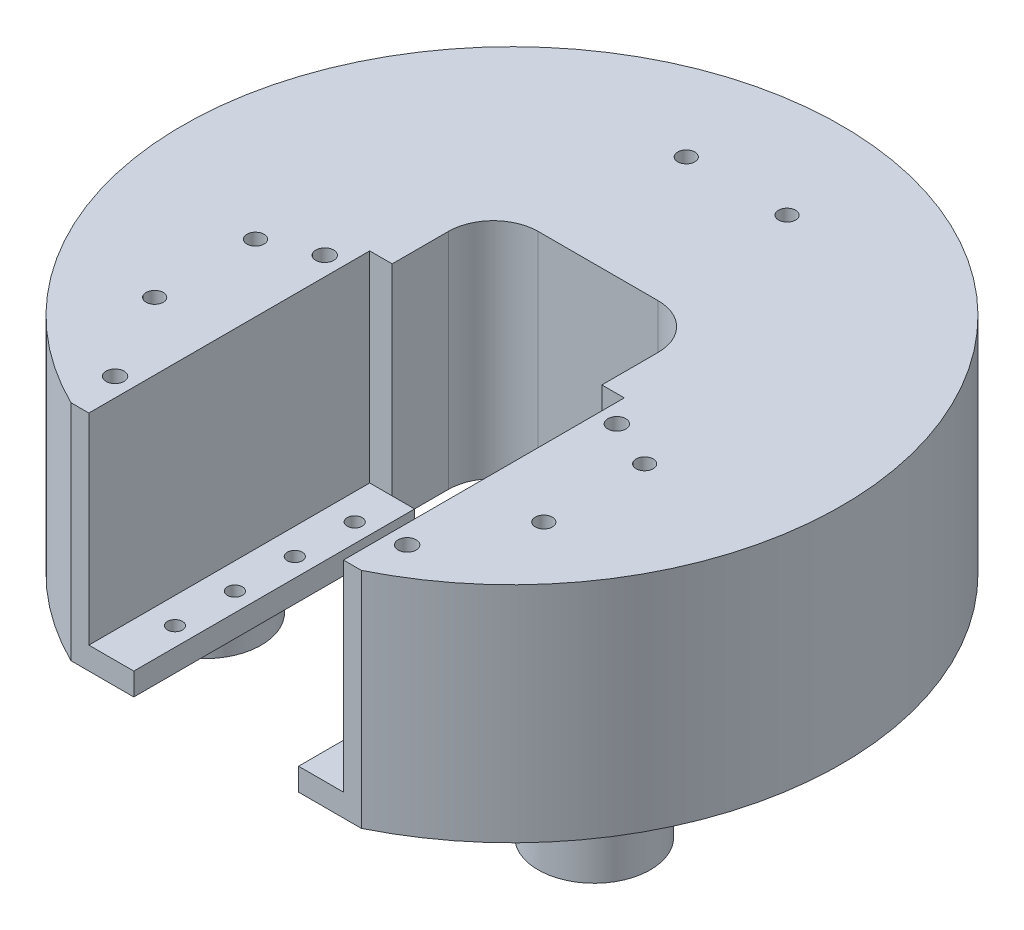
from build123d import *

# Parameters (mm, degrees)
IZIM2_R                                        = 44
Y_KSEKLIK_EKSTR_ZYON1_DEPTH                    = 48
IZIM3_R                                        = 11
KES_EKSTR_ZYON1_DEPTH                          = 35
SERVO_MOTOR_BO_LU_U_REACH                      = 15
IZIM5_R                                        = 5.5
IZIM5_W                                        = 20
IZIM5_H                                        = 6.5
IZIM5_W_2                                      = 6
IZIM5_H_2                                      = 7.2
IZIM6_W                                        = 120
IZIM6_H                                        = 25
KES_EKSTR_ZYON3_DEPTH                          = 49
IZIM7_W                                        = 34
IZIM7_H                                        = 10
KES_EKSTR_ZYON4_DEPTH                          = 37.5
IZIM8_R                                        = 5.5
IZIM8_W                                        = 20
IZIM8_H                                        = 6.5
KES_EKSTR_ZYON5_DEPTH                          = 14
M2_D_Z_BA_L_MAKINE_VIDAS_IN_HAV_A1_D           = 2
M2_D_Z_BA_L_MAKINE_VIDAS_IN_HAV_A1_DEPTH       = 3
M2_D_Z_BA_L_MAKINE_VIDAS_IN_HAV_A1_CSINK_D     = 2.6
M2_D_Z_BA_L_MAKINE_VIDAS_IN_HAV_A1_CSINK_ANGLE = 90
IZIM11_R                                       = 47.5
KES_EKSTR_ZYON6_DEPTH                          = 8.16
IZIM14_R                                       = 47.5
KES_EKSTR_ZYON7_DEPTH                          = 10
IZIM13_R                                       = 7.5
TABAN_AYAKLAR_DEPTH                            = 10
DAIRESEL_KAPLAMA1_COUNT                        = 3
F_3_8_Z_VANA_IN_BORU_Z_VANA_MATKAB_1_D         = 2.286
F_3_8_Z_VANA_IN_BORU_Z_VANA_MATKAB_1_DEPTH     = 10
IZIM18_R                                       = 1.2
KES_EKSTR_ZYON8_DEPTH                          = 10


with BuildPart() as part:
    # Çizim2 → Yükseklik-Ekstrüzyon1 (new body)
    with BuildSketch(Plane(origin=(0, 0, 0), x_dir=(1, 0, 0), z_dir=(0, 1, 0))):
        Circle(IZIM2_R)
    extrude(amount=Y_KSEKLIK_EKSTR_ZYON1_DEPTH)

    # Çizim3 → Kes-Ekstrüzyon1 (cut)
    with BuildSketch(Plane(origin=(0, 48, 0), x_dir=(1, 0, 0), z_dir=(0, 1, 0))):
        Circle(IZIM3_R)
        Polygon((-14, -2), (14, -2), (17, -2), (17, -39.5), (-17, -39.5), (-17, -2), align=None)
        with BuildLine():
            Line((-8, 11.5), (8, 11.5))
            ThreePointArc((8, 11.5), (12.242640687, 9.742640687), (14, 5.5))
            Line((14, 5.5), (14, -2))
            Line((14, -2), (-14, -2))
            Line((-14, -2), (-14, 5.5))
            ThreePointArc((-14, 5.5), (-12.242640687, 9.742640687), (-8, 11.5))
        make_face()
        with BuildLine():
            ThreePointArc((11, 0), (-1.004193186, 10.954067557), (-10.816653826, -2))
            Line((-10.816653826, -2), (10.816653826, -2))
            ThreePointArc((10.816653826, -2), (10.954067557, -1.004193186), (11, 0))
        make_face()
        with BuildLine():
            Line((10.816653826, -2), (-10.816653826, -2))
            ThreePointArc((-10.816653826, -2), (0, -11), (10.816653826, -2))
        make_face()
    extrude(amount=-KES_EKSTR_ZYON1_DEPTH, mode=Mode.SUBTRACT)

    # Çizim5 → Servo Motor Boşluğu (cut, up to next)
    with BuildSketch(Plane(origin=(0, 13, 0), x_dir=(1, 0, 0), z_dir=(0, 1, 0)), mode=Mode.PRIVATE) as servo_motor_bo_lu_u_sk1:
        Circle(IZIM5_R)
    servo_motor_bo_lu_u_tool1 = extrude(servo_motor_bo_lu_u_sk1.sketch, amount=-SERVO_MOTOR_BO_LU_U_REACH, mode=Mode.PRIVATE) & part.part
    add(servo_motor_bo_lu_u_tool1.solids().sort_by_distance((0, 13, 0))[0], mode=Mode.SUBTRACT)
    # Çizim5 → Servo Motor Boşluğu (cut, up to next)
    with BuildSketch(Plane(origin=(0, 13, 0), x_dir=(1, 0, 0), z_dir=(0, 1, 0)), mode=Mode.PRIVATE) as servo_motor_bo_lu_u_sk2:
        with Locations((0, -16.35)):
            Rectangle(IZIM5_W, IZIM5_H)
    servo_motor_bo_lu_u_tool2 = extrude(servo_motor_bo_lu_u_sk2.sketch, amount=-SERVO_MOTOR_BO_LU_U_REACH, mode=Mode.PRIVATE) & part.part
    add(servo_motor_bo_lu_u_tool2.solids().sort_by_distance((0, 13, 16.35))[0], mode=Mode.SUBTRACT)
    # Çizim5 → Servo Motor Boşluğu (cut, up to next)
    with BuildSketch(Plane(origin=(0, 13, 0), x_dir=(1, 0, 0), z_dir=(0, 1, 0)), mode=Mode.PRIVATE) as servo_motor_bo_lu_u_sk3:
        with Locations((-8, -29.9)):
            Rectangle(IZIM5_W_2, IZIM5_H_2)
    servo_motor_bo_lu_u_tool3 = extrude(servo_motor_bo_lu_u_sk3.sketch, amount=-SERVO_MOTOR_BO_LU_U_REACH, mode=Mode.PRIVATE) & part.part
    add(servo_motor_bo_lu_u_tool3.solids().sort_by_distance((-8, 13, 29.9))[0], mode=Mode.SUBTRACT)
    # Çizim5 → Servo Motor Boşluğu (cut, up to next)
    with BuildSketch(Plane(origin=(0, 13, 0), x_dir=(1, 0, 0), z_dir=(0, 1, 0)), mode=Mode.PRIVATE) as servo_motor_bo_lu_u_sk4:
        with Locations((8, -29.9)):
            Rectangle(IZIM5_W_2, IZIM5_H_2)
    servo_motor_bo_lu_u_tool4 = extrude(servo_motor_bo_lu_u_sk4.sketch, amount=-SERVO_MOTOR_BO_LU_U_REACH, mode=Mode.PRIVATE) & part.part
    add(servo_motor_bo_lu_u_tool4.solids().sort_by_distance((8, 13, 29.9))[0], mode=Mode.SUBTRACT)

    # Çizim6 → Kes-Ekstrüzyon3 (cut, through all)
    with BuildSketch(Plane(origin=(0, 48, 0), x_dir=(1, 0, 0), z_dir=(0, 1, 0))):
        with Locations((0, -52)):
            Rectangle(IZIM6_W, IZIM6_H)
    extrude(amount=-KES_EKSTR_ZYON3_DEPTH, mode=Mode.SUBTRACT)

    # Çizim7 → Kes-Ekstrüzyon4 (cut)
    with BuildSketch(Plane.XY.offset(39.5)):
        with Locations((0, 5)):
            Rectangle(IZIM7_W, IZIM7_H)
    extrude(amount=-KES_EKSTR_ZYON4_DEPTH, mode=Mode.SUBTRACT)

    # Çizim8 → Kes-Ekstrüzyon5 (cut, through all)
    with BuildSketch(Plane(origin=(0, 13, 0), x_dir=(1, 0, 0), z_dir=(0, 1, 0))):
        Circle(IZIM8_R)
        with BuildLine():
            Line((14, -2), (11, -2))
            Line((11, -2), (-11, -2))
            Line((-11, -2), (-14, -2))
            Line((-14, -2), (-14, 5.5))
            ThreePointArc((-14, 5.5), (-12.242640687, 9.742640687), (-8, 11.5))
            Line((-8, 11.5), (8, 11.5))
            ThreePointArc((8, 11.5), (12.242640687, 9.742640687), (14, 5.5))
            Line((14, 5.5), (14, -2))
        make_face()
        with BuildLine():
            Line((-5.123475383, -2), (-11, -2))
            Line((-11, -2), (-11, -26.3))
            Line((-11, -26.3), (-5, -26.3))
            Line((-5, -26.3), (-5, -33.5))
            Line((-5, -33.5), (-11, -33.5))
            Line((-11, -33.5), (-11, -39.5))
            Line((-11, -39.5), (11, -39.5))
            Line((11, -39.5), (11, -33.5))
            Line((11, -33.5), (5, -33.5))
            Line((5, -33.5), (5, -26.3))
            Line((5, -26.3), (11, -26.3))
            Line((11, -26.3), (11, -2))
            Line((11, -2), (5.123475383, -2))
            ThreePointArc((5.123475383, -2), (0, -5.5), (-5.123475383, -2))
        make_face()
        with Locations((0, -16.35)):
            Rectangle(IZIM8_W, IZIM8_H, mode=Mode.SUBTRACT)
        with BuildLine():
            ThreePointArc((5.5, 0), (-1.017567048, 5.405049242), (-5.123475383, -2))
            Line((-5.123475383, -2), (5.123475383, -2))
            ThreePointArc((5.123475383, -2), (5.405049242, -1.017567048), (5.5, 0))
        make_face()
        with BuildLine():
            Line((5.123475383, -2), (-5.123475383, -2))
            ThreePointArc((-5.123475383, -2), (0, -5.5), (5.123475383, -2))
        make_face()
    extrude(amount=-KES_EKSTR_ZYON5_DEPTH, mode=Mode.SUBTRACT)

    # M2 Düz Başlı Makine Vidası İçin Havşa1
    with Locations(Plane(origin=(-13.5, 10, 31.5), x_dir=(-1, 0, 0), z_dir=(0, -1, 0))):
        with Locations((0, 0), (0, 8), (0, 16), (0, 24), (-27, 0), (-27, 8), (-27, 16), (-27, 24)):
            CounterSinkHole(M2_D_Z_BA_L_MAKINE_VIDAS_IN_HAV_A1_D / 2, M2_D_Z_BA_L_MAKINE_VIDAS_IN_HAV_A1_CSINK_D / 2, depth=M2_D_Z_BA_L_MAKINE_VIDAS_IN_HAV_A1_DEPTH, counter_sink_angle=M2_D_Z_BA_L_MAKINE_VIDAS_IN_HAV_A1_CSINK_ANGLE)

    # Çizim11 → Kes-Ekstrüzyon6 (cut)
    with BuildSketch(Plane(origin=(0, 48, 0), x_dir=(1, 0, 0), z_dir=(0, 1, 0))):
        Circle(IZIM11_R)
    extrude(amount=-KES_EKSTR_ZYON6_DEPTH, mode=Mode.SUBTRACT)

    # Çizim14 → Kes-Ekstrüzyon7 (cut)
    with BuildSketch(Plane.XZ):
        Circle(IZIM14_R)
    extrude(amount=-KES_EKSTR_ZYON7_DEPTH, mode=Mode.SUBTRACT)

    # Çizim13 → Taban Ayakları (add)
    with BuildSketch(Plane.XZ):
        with Locations((0, -30)):
            Circle(IZIM13_R)
    taban_ayaklar = extrude(amount=-TABAN_AYAKLAR_DEPTH)

    # Dairesel Kaplama1: Taban Ayakları ×3 about axis
    dairesel_kaplama1_axis = Axis((0, 0, 0), (0, 1, 0))
    for i in range(1, DAIRESEL_KAPLAMA1_COUNT):
        add(taban_ayaklar.rotate(dairesel_kaplama1_axis, i * 360 / DAIRESEL_KAPLAMA1_COUNT))

    # 3/8 Zıvana İçin Boru Zıvana Matkabı1
    with Locations(Plane(origin=(-6.731, 39.84, -30), x_dir=(0, 0, 1), z_dir=(0, 1, 0))):
        with Locations((0, 0), (0, 13.462), (38.269, -19.249762114), (51.731, -19.249762114), (38.269, 32.711762114), (51.731, 32.711762114)):
            Hole(F_3_8_Z_VANA_IN_BORU_Z_VANA_MATKAB_1_D / 2, depth=F_3_8_Z_VANA_IN_BORU_Z_VANA_MATKAB_1_DEPTH)

    # Çizim18 → Kes-Ekstrüzyon8 (cut)
    with BuildSketch(Plane(origin=(0, 39.84, 0), x_dir=(1, 0, 0), z_dir=(0, 1, 0))):
        with Locations((-19.5, -5.5)):
            Circle(IZIM18_R)
        with Locations((-19.5, -33.5)):
            Circle(IZIM18_R)
        with Locations((19.5, -5.5)):
            Circle(IZIM18_R)
        with Locations((19.5, -33.5)):
            Circle(IZIM18_R)
    extrude(amount=-KES_EKSTR_ZYON8_DEPTH, mode=Mode.SUBTRACT)


solid = part.part
